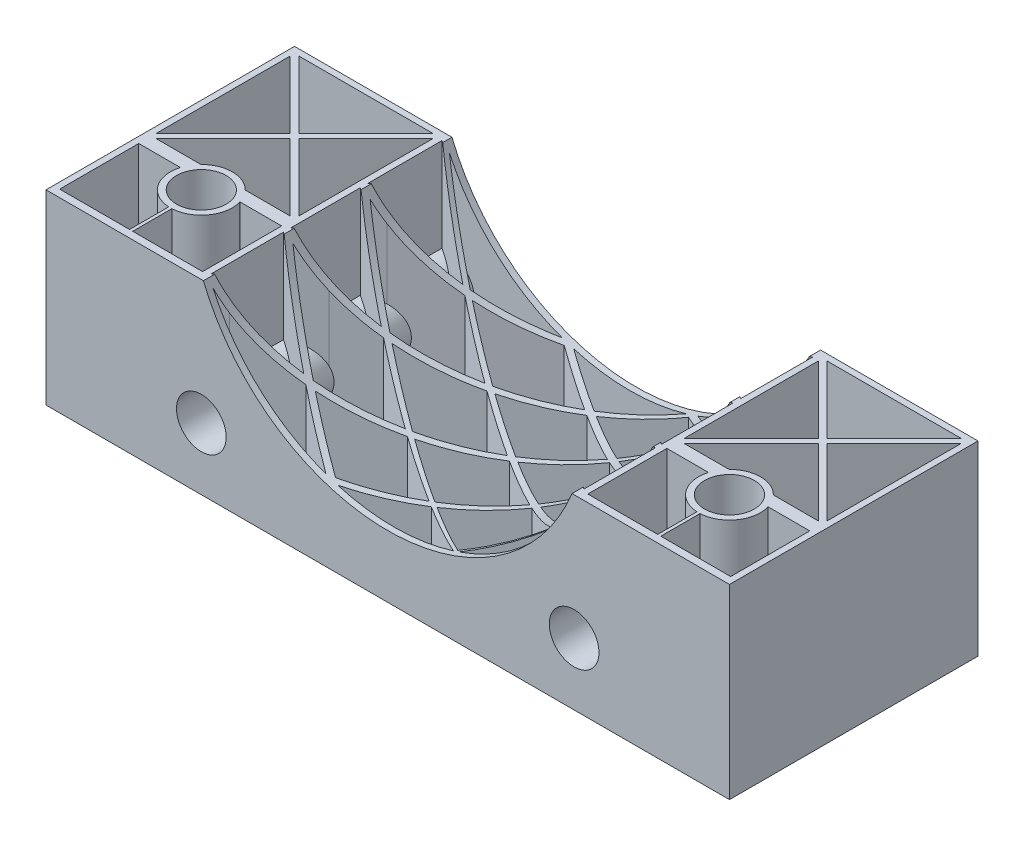
from build123d import *

# Parameters (mm, degrees)
SKETCH1_W           = 110
SKETCH1_H           = 40
BOSS_EXTRUDE1_DEPTH = 30
SKETCH2_R           = 32
CUT_EXTRUDE1_DEPTH  = 40
SKETCH3_R           = 4
CUT_EXTRUDE3_DEPTH  = 30
SKETCH7_R           = 4
CUT_EXTRUDE6_DEPTH  = 40
CUT_EXTRUDE7_DEPTH  = 30
CUT_EXTRUDE9_DEPTH  = 30
SKETCH12_R          = 5
BOSS_EXTRUDE3_DEPTH = 40
SKETCH15_R          = 4
CUT_EXTRUDE10_DEPTH = 40


with BuildPart() as part:
    # Sketch1 → Boss-Extrude1 (new body)
    with BuildSketch(Plane(origin=(0, 0, 0), x_dir=(1, 0, 0), z_dir=(0, 1, 0))):
        with Locations((55, 20)):
            Rectangle(SKETCH1_W, SKETCH1_H)
    extrude(amount=BOSS_EXTRUDE1_DEPTH)

    # Sketch2 → Cut-Extrude1 (cut)
    with BuildSketch(Plane.XY):
        with Locations((55, 42)):
            Circle(SKETCH2_R)
    extrude(amount=-CUT_EXTRUDE1_DEPTH, mode=Mode.SUBTRACT)

    # Sketch3 → Cut-Extrude3 (cut)
    with BuildSketch(Plane.XZ):
        with Locations((12.5, -12.5)):
            Circle(SKETCH3_R)
    cut_extrude3 = extrude(amount=-CUT_EXTRUDE3_DEPTH, mode=Mode.SUBTRACT)

    # Mirror1: Cut-Extrude3 across plane
    add(cut_extrude3.mirror(Plane(origin=(55, 0, 0), x_dir=(0, 0, 1), z_dir=(1, 0, 0))), mode=Mode.SUBTRACT)

    # Sketch7 → Cut-Extrude6 (cut)
    with BuildSketch(Plane.XY):
        with Locations((25, 10)):
            Circle(SKETCH7_R)
        with Locations((85, 10)):
            Circle(SKETCH7_R)
    extrude(amount=-CUT_EXTRUDE6_DEPTH, mode=Mode.SUBTRACT)

    # Sketch9 → Cut-Extrude7 (cut)
    with BuildSketch(Plane.XZ):
        Polygon((1.707106781, -39), (12.5, -28.207106781), (23.292893219, -39), (21.79125531, -39), align=None)
        Polygon((1, -16.707106781), (11.792893219, -27.5), (1, -38.292893219), (1, -36.79125531), align=None)
        with BuildLine():
            Line((23.292893219, -16), (12.5, -26.792893219))
            Line((12.5, -26.792893219), (1.707106781, -16))
            Line((1.707106781, -16), (8.929285786, -16))
            ThreePointArc((8.929285786, -16), (12.5, -17.5), (16.070714214, -16))
            Line((16.070714214, -16), (23.292893219, -16))
        make_face()
        Polygon((24, -38.292893219), (13.207106781, -27.5), (24, -16.707106781), (24, -18.20874469), align=None)
        with BuildLine():
            Line((12.25, -1.199621128), (1, -1.199621128))
            Line((1, -1.199621128), (1, -13.924921606))
            Line((1, -13.924921606), (7.707339109, -13.924921606))
            Line((7.707339109, -13.924921606), (7.68918539, -13.862373953))
            ThreePointArc((7.68918539, -13.862373953), (8.437608263, -9.585043161), (12.25, -7.506253911))
            Line((12.25, -7.506253911), (12.25, -1.199621128))
        make_face()
        with BuildLine():
            Line((17.292660891, -13.924921606), (17.31081461, -13.862373953))
            ThreePointArc((17.31081461, -13.862373953), (16.562391737, -9.585043161), (12.75, -7.506253911))
            Line((12.75, -7.506253911), (12.75, -1.199621128))
            Line((12.75, -1.199621128), (24, -1.199621128))
            Line((24, -1.199621128), (24, -13.924921606))
            Line((24, -13.924921606), (17.292660891, -13.924921606))
        make_face()
        with BuildLine():
            Line((97.25, -1.199621128), (86, -1.199621128))
            Line((86, -1.199621128), (86, -13.924921606))
            Line((86, -13.924921606), (92.707339109, -13.924921606))
            Line((92.707339109, -13.924921606), (92.68918539, -13.862373953))
            ThreePointArc((92.68918539, -13.862373953), (93.437608263, -9.585043161), (97.25, -7.506253911))
            Line((97.25, -7.506253911), (97.25, -1.199621128))
        make_face()
        with BuildLine():
            Line((102.292660891, -13.924921606), (102.31081461, -13.862373953))
            ThreePointArc((102.31081461, -13.862373953), (101.562391737, -9.585043161), (97.75, -7.506253911))
            Line((97.75, -7.506253911), (97.75, -1.199621128))
            Line((97.75, -1.199621128), (109, -1.199621128))
            Line((109, -1.199621128), (109, -13.924921606))
            Line((109, -13.924921606), (102.292660891, -13.924921606))
        make_face()
        with BuildLine():
            Line((93.929285786, -16), (86.707106781, -16))
            Line((86.707106781, -16), (97.5, -26.792893219))
            Line((97.5, -26.792893219), (108.292893219, -16))
            Line((108.292893219, -16), (101.070714214, -16))
            ThreePointArc((101.070714214, -16), (97.5, -17.5), (93.929285786, -16))
        make_face()
        Polygon((86, -38.292893219), (86, -18.20874469), (86, -16.707106781), (96.792893219, -27.5), align=None)
        Polygon((109, -16.707106781), (109, -36.79125531), (109, -38.292893219), (98.207106781, -27.5), align=None)
        Polygon((86.707106781, -39), (88.20874469, -39), (108.292893219, -39), (97.5, -28.207106781), align=None)
    extrude(amount=-CUT_EXTRUDE7_DEPTH, mode=Mode.SUBTRACT)

    # Sketch11 → Cut-Extrude9 (cut)
    with BuildSketch(Plane.XZ):
        Polygon((74.831777691, -6.870491009), (84.013970911, -1), (65.436435115, -1), align=None)
        Polygon((85, -13.007711008), (85, -1.591842697), (75.754730915, -7.447179784), (84.828397962, -13.116678302), align=None)
        Polygon((74.303109193, -7.20848691), (65.00347679, -1.276449032), (55.748894389, -7.18560979), (65.113625115, -13.083639214), align=None)
        Polygon((55.184396802, -6.830081855), (64.570088732, -1), (45.92755138, -1), align=None)
        Polygon((75.037558184, -19.333861561), (84.195449509, -13.51860057), (75.214092745, -7.789583958), (65.986768251, -13.633556138), align=None)
        Polygon((85, -25.608337217), (85, -14.03180623), (81.349745928, -16.510200328), (75.974121895, -19.923721588), align=None)
        Polygon((47.722877132, -3.306365214), (45.005975516, -1.589808553), (35.983357785, -7.364283901), (45.064941258, -13.115953433), (54.24364247, -7.414447377), align=None)
        Polygon((64.184872748, -13.677422452), (54.820920186, -7.778132338), (45.765881351, -13.559882159), (55.111159638, -19.478558407), align=None)
        Polygon((74.104156828, -19.926571422), (65.053474994, -14.224641867), (55.934488469, -20), (64.973366916, -25.724623017), align=None)
        Polygon((35.050950115, -6.773759043), (44.07244862, -1), (25.860015592, -1), (27.529634929, -2.010259425), align=None)
        Polygon((80.649584856, -28.390632809), (84.068474608, -26.204091624), (75.040582112, -20.516519351), (65.907331161, -26.316133705), (74.946238074, -32.04077475), align=None)
        Polygon((54.181077526, -20.073191796), (44.835197816, -14.154134647), (35.728490581, -19.968875355), (45.103769575, -25.876626056), align=None)
        Polygon((85, -38.408157303), (85, -26.790952621), (82.228397155, -28.567458704), (75.878645743, -32.631299607), align=None)
        Polygon((64.040106421, -26.31724343), (55, -20.591842697), (45.881647659, -26.36679918), (54.956574992, -32.085285888), align=None)
        Polygon((44.12138996, -13.702056338), (35.053761926, -7.95922525), (28.423168594, -12.202804983), (25.932883022, -13.794637913), (29.509301375, -16.049907246), (34.886630018, -19.438384226), align=None)
        Polygon((34.121354257, -7.368700393), (25, -1.591842697), (25, -13.206367117), align=None)
        Polygon((44.174383673, -26.470814335), (34.797457648, -20.563350939), (25.961839119, -26.204998289), (27.626895365, -27.28758015), (35.257903909, -32.171425619), align=None)
        Polygon((66.85354378, -37.220099098), (74.016642215, -32.635716099), (64.974070666, -26.908754119), (55.892895673, -32.67530024), (64.990420354, -38.408026471), align=None)
        Polygon((54.025105444, -32.676769051), (44.947934097, -26.958151102), (35.983357785, -32.635716099), (45.001054032, -38.407041698), align=None)
        Polygon((25, -25.579632277), (33.942595105, -20.024787537), (25, -14.390952621), align=None)
        Polygon((65.929850142, -39), (84.065511531, -39), (74.949049885, -33.226240957), (67.451195268, -38.024867912), align=None)
        Polygon((25, -38.729655361), (34.329869874, -32.764749603), (26.854833561, -27.980726362), (25, -26.819143988), align=None)
        Polygon((64.061979967, -39), (54.961530728, -33.26671698), (47.140316953, -38.233187727), (45.92755138, -39), align=None)
        Polygon((42.539405901, -38.01885266), (35.050950115, -33.226240957), (25.934488469, -39), (44.06726143, -39), align=None)
    extrude(amount=-CUT_EXTRUDE9_DEPTH, mode=Mode.SUBTRACT)

    # Sketch12 → Boss-Extrude3 (add)
    with BuildSketch(Plane.XY):
        with Locations((25, 10)):
            Circle(SKETCH12_R)
        with Locations((85, 10)):
            Circle(SKETCH12_R)
    extrude(amount=-BOSS_EXTRUDE3_DEPTH)

    # Sketch15 → Cut-Extrude10 (cut)
    with BuildSketch(Plane.XY):
        with Locations((25, 10)):
            Circle(SKETCH15_R)
        with Locations((85, 10)):
            Circle(SKETCH15_R)
    extrude(amount=-CUT_EXTRUDE10_DEPTH, mode=Mode.SUBTRACT)


solid = part.part
